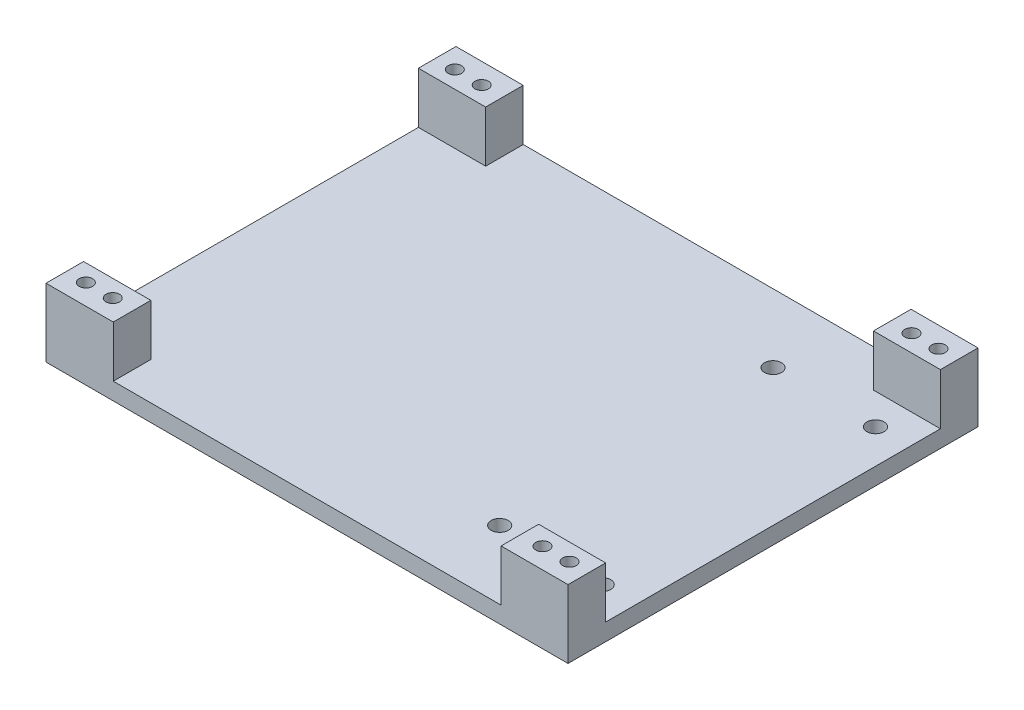
from build123d import *

# Parameters (mm, degrees)
SKETCH2_W           = 194.056
SKETCH2_H           = 152.4
BOSS_EXTRUDE1_DEPTH = 6.35
SKETCH3_R           = 3.175
CUT_EXTRUDE1_DEPTH  = 6.35
SKETCH4_W           = 24.892
SKETCH4_H           = 13.97
SKETCH4_W_2         = 25
BOSS_EXTRUDE2_DEPTH = 19.05
SKETCH5_R           = 2.5
CUT_EXTRUDE2_DEPTH  = 26.4


with BuildPart() as part:
    # Sketch2 → Boss-Extrude1 (new body)
    with BuildSketch(Plane(origin=(0, 0, 0), x_dir=(1, 0, 0), z_dir=(0, 1, 0))):
        with Locations((-43.688, -19.614444444)):
            Rectangle(SKETCH2_W, SKETCH2_H)
    extrude(amount=BOSS_EXTRUDE1_DEPTH)

    # Sketch3 → Cut-Extrude1 (cut)
    with BuildSketch(Plane(origin=(0, 6.35, 0), x_dir=(1, 0, 0), z_dir=(0, 1, 0))):
        with Locations((2.54, -70.414444444)):
            Circle(SKETCH3_R)
        with Locations((2.54, 31.185555556)):
            Circle(SKETCH3_R)
        with Locations((40.64, 31.185555556)):
            Circle(SKETCH3_R)
        with Locations((40.64, -70.414444444)):
            Circle(SKETCH3_R)
    extrude(amount=-CUT_EXTRUDE1_DEPTH, mode=Mode.SUBTRACT)

    # Sketch4 → Boss-Extrude2 (add)
    with BuildSketch(Plane(origin=(0, 6.35, 0), x_dir=(1, 0, 0), z_dir=(0, 1, 0))):
        with Locations((40.894, -88.829444444)):
            Rectangle(SKETCH4_W, SKETCH4_H)
        with Locations((-128.216, -88.829444444)):
            Rectangle(SKETCH4_W_2, SKETCH4_H)
        with Locations((-128.216, 49.600555556)):
            Rectangle(SKETCH4_W_2, SKETCH4_H)
        with Locations((40.894, 49.600555556)):
            Rectangle(SKETCH4_W, SKETCH4_H)
    extrude(amount=BOSS_EXTRUDE2_DEPTH)

    # Sketch5 → Cut-Extrude2 (cut, through all)
    with BuildSketch(Plane(origin=(0, 25.4, 0), x_dir=(1, 0, 0), z_dir=(0, 1, 0))):
        with Locations((-133.526, -88.194444444)):
            Circle(SKETCH5_R)
        with Locations((-123.526, -88.194444444)):
            Circle(SKETCH5_R)
        with Locations((-133.526, 48.965555556)):
            Circle(SKETCH5_R)
        with Locations((-123.526, 48.965555556)):
            Circle(SKETCH5_R)
        with Locations((36.258, 48.965555556)):
            Circle(SKETCH5_R)
        with Locations((46.258, 48.965555556)):
            Circle(SKETCH5_R)
        with Locations((36.258, -88.194444444)):
            Circle(SKETCH5_R)
        with Locations((46.258, -88.194444444)):
            Circle(SKETCH5_R)
    extrude(amount=-CUT_EXTRUDE2_DEPTH, mode=Mode.SUBTRACT)


solid = part.part
